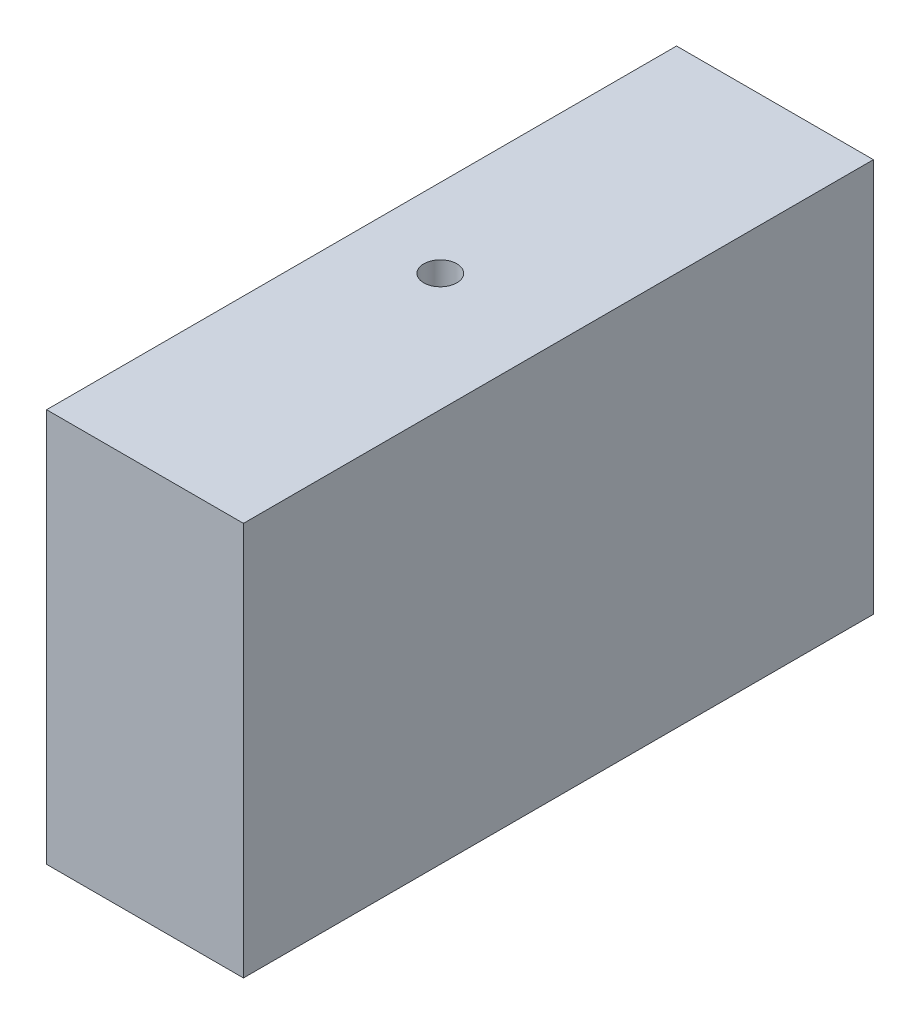
from build123d import *

# Parameters (mm, degrees)
CROQUIS1_W                                     = 25
CROQUIS1_H                                     = 50
SALIENTE_EXTRUIR1_DEPTH                        = 80
PERFORADOR_PARA_ROSCAR_PARA_MACHO_DE_ROS_D     = 4.2
PERFORADOR_PARA_ROSCAR_PARA_MACHO_DE_ROS_DEPTH = 11
PERFORADOR_PARA_ROSCAR_PARA_MACHO_DE_ROS_TIP   = 1.2618073
PERFORADOR_PARA_ROSCAR_PARA_MACHO_DE_2_D       = 4.2
PERFORADOR_PARA_ROSCAR_PARA_MACHO_DE_2_DEPTH   = 11
PERFORADOR_PARA_ROSCAR_PARA_MACHO_DE_2_TIP     = 1.2618073


with BuildPart() as part:
    # Croquis1 → Saliente-Extruir1 (new body)
    with BuildSketch(Plane.XY):
        with Locations((-19.131816286, 7.30620438)):
            Rectangle(CROQUIS1_W, CROQUIS1_H)
    extrude(amount=SALIENTE_EXTRUIR1_DEPTH)

    # Perforador para roscar para macho de ros
    with Locations(Plane(origin=(-21.631816286, 32.30620438, 40), x_dir=(0, 0, 1), z_dir=(0, 1, 0))):
        with Locations((0, 0)):
            Hole(PERFORADOR_PARA_ROSCAR_PARA_MACHO_DE_ROS_D / 2, depth=PERFORADOR_PARA_ROSCAR_PARA_MACHO_DE_ROS_DEPTH)
            with Locations((0, 0, -(PERFORADOR_PARA_ROSCAR_PARA_MACHO_DE_ROS_DEPTH + PERFORADOR_PARA_ROSCAR_PARA_MACHO_DE_ROS_TIP / 2))):  # 118° drill point
                Cone(0, PERFORADOR_PARA_ROSCAR_PARA_MACHO_DE_ROS_D / 2, PERFORADOR_PARA_ROSCAR_PARA_MACHO_DE_ROS_TIP, mode=Mode.SUBTRACT)

    # Perforador para roscar para macho de 2
    with Locations(Plane(origin=(-21.631816286, -17.69379562, 40), x_dir=(0, 0, -1), z_dir=(0, -1, 0))):
        with Locations((0, 0)):
            Hole(PERFORADOR_PARA_ROSCAR_PARA_MACHO_DE_2_D / 2, depth=PERFORADOR_PARA_ROSCAR_PARA_MACHO_DE_2_DEPTH)
            with Locations((0, 0, -(PERFORADOR_PARA_ROSCAR_PARA_MACHO_DE_2_DEPTH + PERFORADOR_PARA_ROSCAR_PARA_MACHO_DE_2_TIP / 2))):  # 118° drill point
                Cone(0, PERFORADOR_PARA_ROSCAR_PARA_MACHO_DE_2_D / 2, PERFORADOR_PARA_ROSCAR_PARA_MACHO_DE_2_TIP, mode=Mode.SUBTRACT)


solid = part.part
